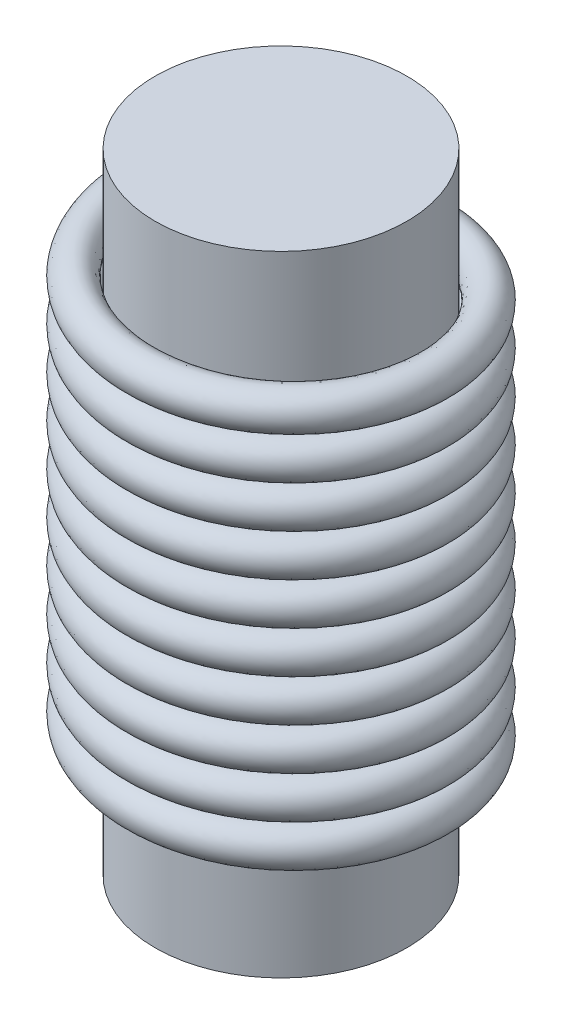
from build123d import *

# Parameters (mm, degrees)
SKETCH1_R                = 3
BOSS_EXTRUDE1_DEPTH      = 12.5
BOSS_EXTRUDE1_DEPTH_BACK = 2.5
SWEEP1_PITCH             = 1
SWEEP1_HEIGHT            = 10
SWEEP1_RADIUS            = 3.5
SWEEP1_START_ANGLE       = -90
SKETCH3_R                = 0.45


with BuildPart() as part:
    # Sketch1 → Boss-Extrude1 (new body, two sides)
    with BuildSketch(Plane(origin=(0, 0, 0), x_dir=(1, 0, 0), z_dir=(0, 1, 0))) as boss_extrude1_sk:
        Circle(SKETCH1_R)
    extrude(amount=BOSS_EXTRUDE1_DEPTH)
    extrude(boss_extrude1_sk.sketch, amount=-BOSS_EXTRUDE1_DEPTH_BACK)


with BuildPart() as body_2:
    # Sweep1: sweep along a helix
    with BuildLine() as sweep1_path:
        add(Helix(SWEEP1_PITCH, SWEEP1_HEIGHT, SWEEP1_RADIUS, center=(0, 0, 0), direction=(0, 1, 0), lefthand=True, mode=Mode.PRIVATE).rotate(Axis((0, 0, 0), (0, 1, 0)), SWEEP1_START_ANGLE))
    # Sketch3 → Sweep1 (sweep)
    with BuildSketch(Plane.XY):
        with Locations((-3.5, 0)):
            Circle(SKETCH3_R)
    sweep(path=sweep1_path.line, is_frenet=True)


solid = Compound([part.part, body_2.part])
